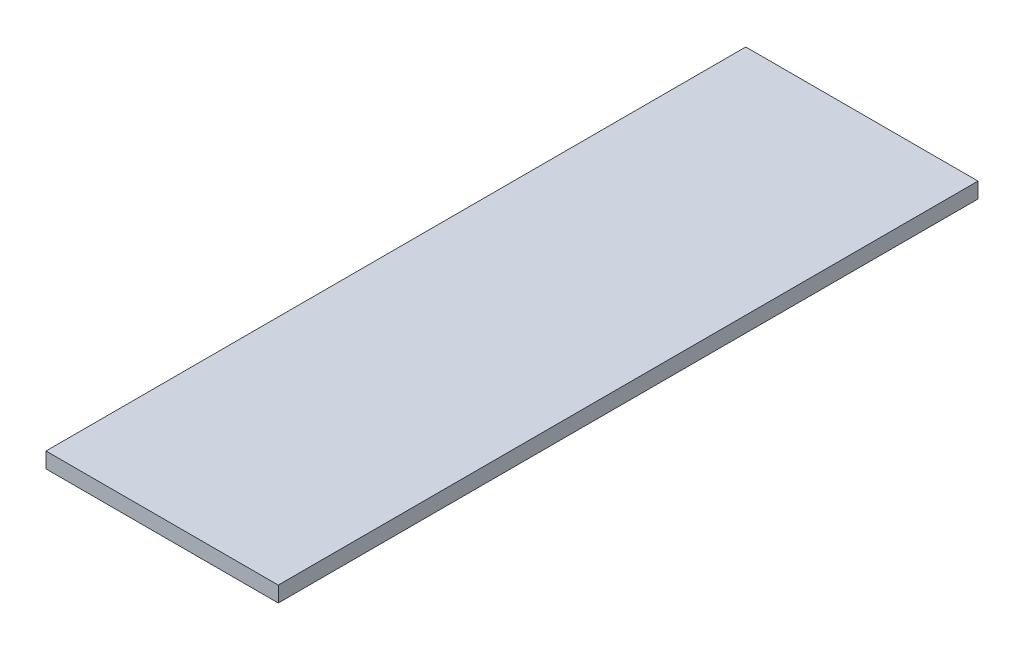
from build123d import *

# Parameters (mm, degrees)
SKIZZE1_W                       = 149.358259494
SKIZZE1_H                       = 10
AUFSATZ_LINEAR_AUSTRAGEN1_DEPTH = 450


with BuildPart() as part:
    # Skizze1 → Aufsatz-Linear austragen1 (new body)
    with BuildSketch(Plane.XY):
        with Locations((257.179129747, 0)):
            Rectangle(SKIZZE1_W, SKIZZE1_H)
    extrude(amount=AUFSATZ_LINEAR_AUSTRAGEN1_DEPTH)


solid = part.part
